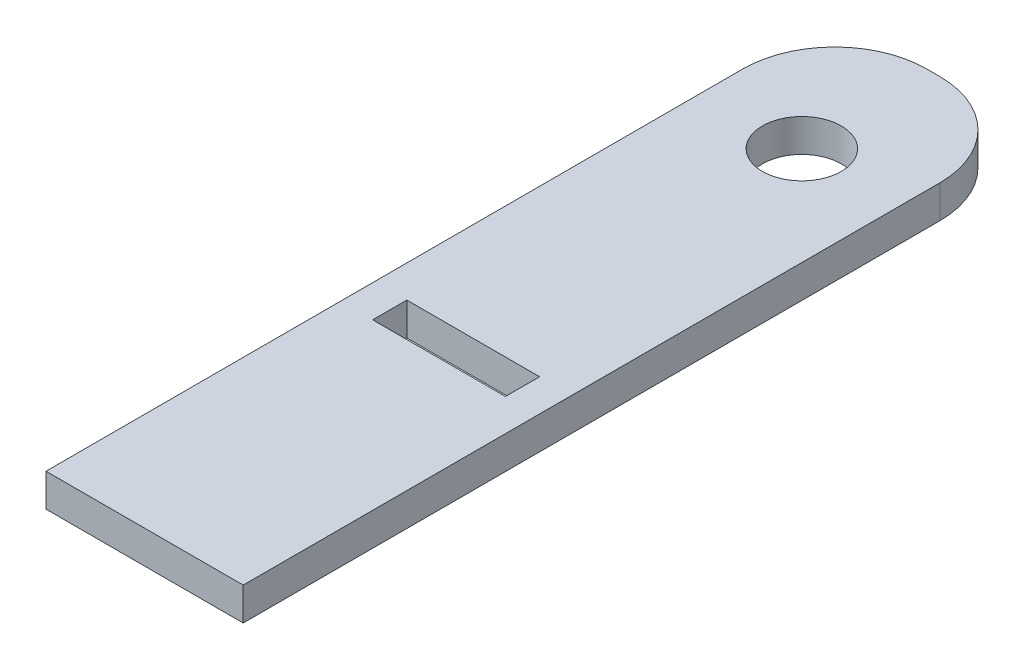
from build123d import *

# Parameters (mm, degrees)
SKETCH1_W           = 19.05
SKETCH1_H           = 76.2
SKETCH1_R           = 3.81
SKETCH1_W_2         = 12.827
SKETCH1_H_2         = 3.302
BOSS_EXTRUDE1_DEPTH = 3.175
FILLET1_R           = 8.89
FILLET2_R           = 8.89


with BuildPart() as part:
    # Sketch1 → Boss-Extrude1 (new body)
    with BuildSketch(Plane(origin=(0, 0, 0), x_dir=(1, 0, 0), z_dir=(0, 1, 0))):
        Rectangle(SKETCH1_W, SKETCH1_H)
        with Locations((0, 25.4)):
            Circle(SKETCH1_R, mode=Mode.SUBTRACT)
        with Locations((0, -8.001)):
            Rectangle(SKETCH1_W_2, SKETCH1_H_2, mode=Mode.SUBTRACT)
    extrude(amount=BOSS_EXTRUDE1_DEPTH)

    # Fillet1
    fillet1_edges = [part.edges().sort_by_distance(p)[0] for p in [
        (9.525, 1.5875, -38.1),
    ]]
    fillet(fillet1_edges, radius=FILLET1_R)

    # Fillet2
    fillet2_edges = [part.edges().sort_by_distance(p)[0] for p in [
        (-9.525, 1.5875, -38.1),
    ]]
    fillet(fillet2_edges, radius=FILLET2_R)


solid = part.part
